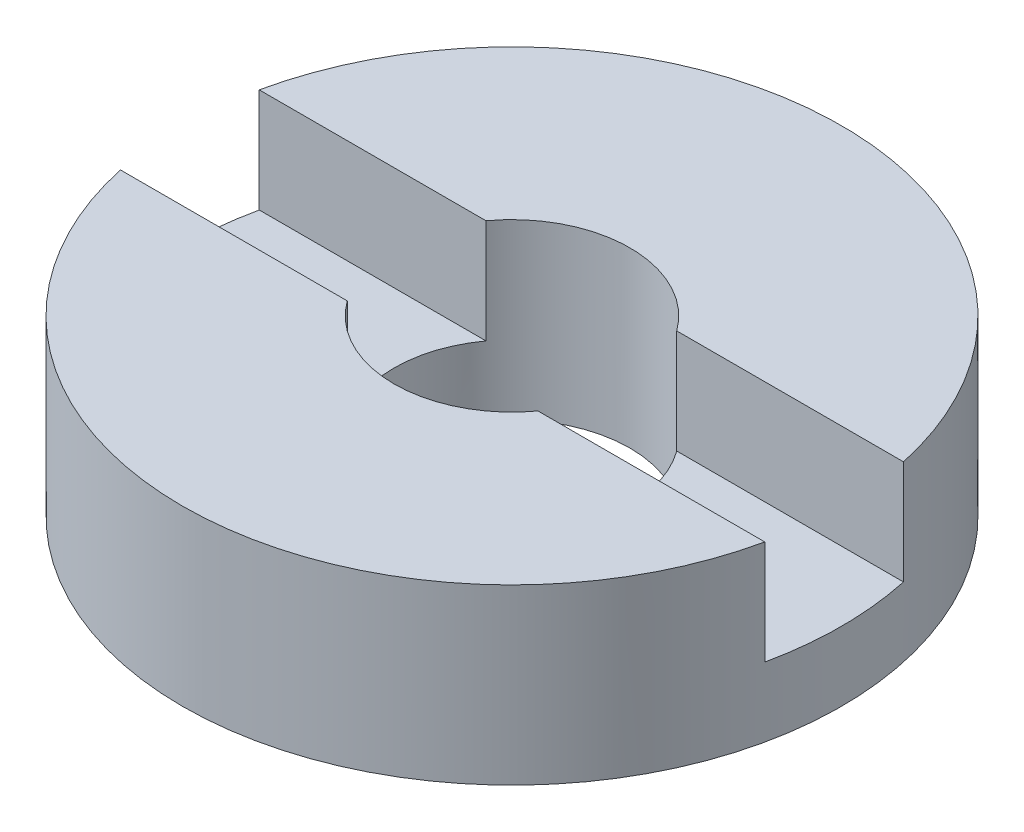
from build123d import *

# Parameters (mm, degrees)
SKETCH_1_W          = 3.05
SKETCH_1_H          = 2.5
SKETCH_2_W          = 53.705080546
SKETCH_2_H          = 2
CUT_EXTRUDE_1_DEPTH = 1.5


with BuildPart() as part:
    # 草图1 → 旋转1 (revolve)
    with BuildSketch(Plane.XY, mode=Mode.PRIVATE) as revolve_1_sk:
        with Locations((3.225, -3.214249787)):
            Rectangle(SKETCH_1_W, SKETCH_1_H)
    revolve(revolve_1_sk.sketch.rotate(Axis((0, 56.260842627, 0), (0, -1, 0)), 90), axis=Axis((0, 56.260842627, 0), (0, -1, 0)))  # turned: the seam where the file's is

    # 草图2 → 切除-拉伸1 (cut)
    with BuildSketch(Plane(origin=(0, -1.964249787, 0), x_dir=(1, 0, 0), z_dir=(0, 1, 0))):
        Rectangle(SKETCH_2_W, SKETCH_2_H)
    extrude(amount=-CUT_EXTRUDE_1_DEPTH, mode=Mode.SUBTRACT)


solid = part.part
